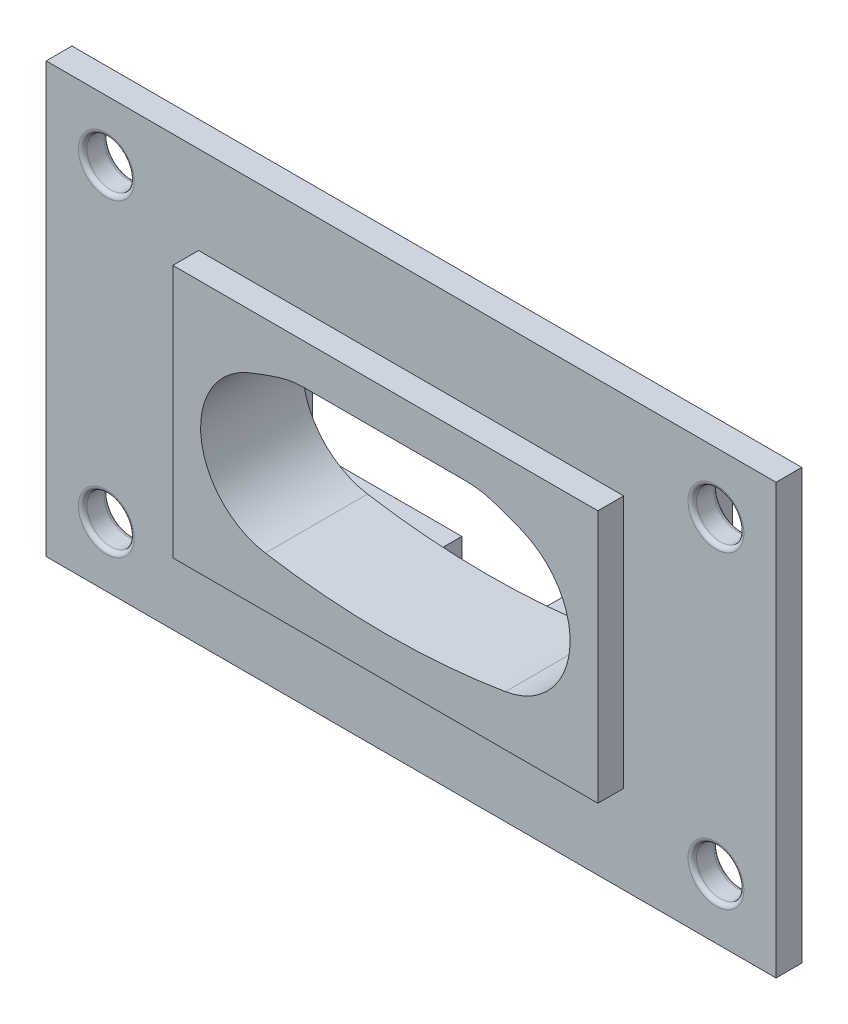
from build123d import *

# Parameters (mm, degrees)
SKETCH1_W           = 51
SKETCH1_H           = 26
BOSS_EXTRUDE1_DEPTH = 5.9
SKETCH3_W           = 85
SKETCH3_H           = 50
SKETCH3_R           = 2.75
BOSS_EXTRUDE2_DEPTH = 3
SKETCH4_W           = 49.5
SKETCH4_H           = 29.5
BOSS_EXTRUDE3_DEPTH = 3
FILLET1_R           = 0.5
BOSS_EXTRUDE4_DEPTH = 11.9
FILLET2_R           = 10
BOSS_EXTRUDE5_DEPTH = 3
FILLET3_R           = 1


with BuildPart() as part:
    # Sketch1 → Boss-Extrude1 (new body)
    with BuildSketch(Plane.XY):
        Rectangle(SKETCH1_W, SKETCH1_H)
        with BuildLine():
            ThreePointArc((-15.997874486, 8.30002236), (-21.456449092, -1.050649716), (-13.978406554, -8.880718987))
            ThreePointArc((-13.978406554, -8.880718987), (0, -10.022415929), (13.978406554, -8.880718987))
            ThreePointArc((13.978406554, -8.880718987), (21.456449092, -1.050649716), (15.997874486, 8.30002236))
            ThreePointArc((15.997874486, 8.30002236), (0, 11.517985288), (-15.997874486, 8.30002236))
        make_face(mode=Mode.SUBTRACT)
    extrude(amount=BOSS_EXTRUDE1_DEPTH)

    # Sketch3 → Boss-Extrude2 (add)
    with BuildSketch(Plane.XY.offset(5.9)):
        Rectangle(SKETCH3_W, SKETCH3_H)
        with Locations((-35.5, 18)):
            Circle(SKETCH3_R, mode=Mode.SUBTRACT)
        with Locations((35.5, 18)):
            Circle(SKETCH3_R, mode=Mode.SUBTRACT)
        with Locations((35.5, -18)):
            Circle(SKETCH3_R, mode=Mode.SUBTRACT)
        with Locations((-35.5, -18)):
            Circle(SKETCH3_R, mode=Mode.SUBTRACT)
        with BuildLine():
            ThreePointArc((-13.978406554, -8.880718987), (0, -10.022415929), (13.978406554, -8.880718987))
            ThreePointArc((13.978406554, -8.880718987), (21.456449092, -1.050649716), (15.997874486, 8.30002236))
            ThreePointArc((15.997874486, 8.30002236), (0, 11.517985288), (-15.997874486, 8.30002236))
            ThreePointArc((-15.997874486, 8.30002236), (-21.456449092, -1.050649716), (-13.978406554, -8.880718987))
        make_face(mode=Mode.SUBTRACT)
    extrude(amount=BOSS_EXTRUDE2_DEPTH)

    # Sketch4 → Boss-Extrude3 (add)
    with BuildSketch(Plane.XY.offset(8.9)):
        Rectangle(SKETCH4_W, SKETCH4_H)
        with BuildLine():
            ThreePointArc((-13.978406554, -8.880718987), (0, -10.022415929), (13.978406554, -8.880718987))
            ThreePointArc((13.978406554, -8.880718987), (21.456449092, -1.050649716), (15.997874486, 8.30002236))
            ThreePointArc((15.997874486, 8.30002236), (0, 11.517985288), (-15.997874486, 8.30002236))
            ThreePointArc((-15.997874486, 8.30002236), (-21.456449092, -1.050649716), (-13.978406554, -8.880718987))
        make_face(mode=Mode.SUBTRACT)
    extrude(amount=BOSS_EXTRUDE3_DEPTH)

    # Fillet1
    fillet1_edges = [part.edges().sort_by_distance(p)[0] for p in [
        (32.75, -18, 5.9),
        (-38.25, 18, 5.9),
        (32.75, 18, 5.9),
        (-38.25, -18, 5.9),
        (-38.25, 18, 8.9),
        (32.75, 18, 8.9),
        (32.75, -18, 8.9),
        (-38.25, -18, 8.9),
    ]]
    fillet(fillet1_edges, radius=FILLET1_R)

    # Sketch6 → Boss-Extrude4 (add)
    with BuildSketch(Plane(origin=(0, 0, 0), x_dir=(-1, 0, 0), z_dir=(0, 0, -1))):
        with BuildLine():
            Line((-10.850092151, 10.07), (10.850092151, 10.07))
            ThreePointArc((10.850092151, 10.07), (0, 11.517985288), (-10.850092151, 10.07))
        make_face()
    extrude(amount=-BOSS_EXTRUDE4_DEPTH)

    # Fillet2
    fillet2_edges = [part.edges().sort_by_distance(p)[0] for p in [
        (10.850092151, 10.07, 5.95),
        (-10.850092151, 10.07, 5.95),
    ]]
    fillet(fillet2_edges, radius=FILLET2_R)

    # Sketch7 → Boss-Extrude5 (add)
    with BuildSketch(Plane(origin=(0, 0, 0), x_dir=(-1, 0, 0), z_dir=(0, 0, -1))):
        Polygon((-23.36, -10.66), (-23.36, 10.66), (23.36, 10.66), (23.36, -10.66), (6, -10.66), (6, -13), (25.5, -13), (25.5, 13), (-25.5, 13), (-25.5, -13), (-6, -13), (-6, -10.66), align=None)
    extrude(amount=BOSS_EXTRUDE5_DEPTH)

    # Fillet3
    fillet3_edges = [part.edges().sort_by_distance(p)[0] for p in [
        (-6, -11.83, 0),
        (6, -11.83, 0),
    ]]
    fillet(fillet3_edges, radius=FILLET3_R)


solid = part.part
